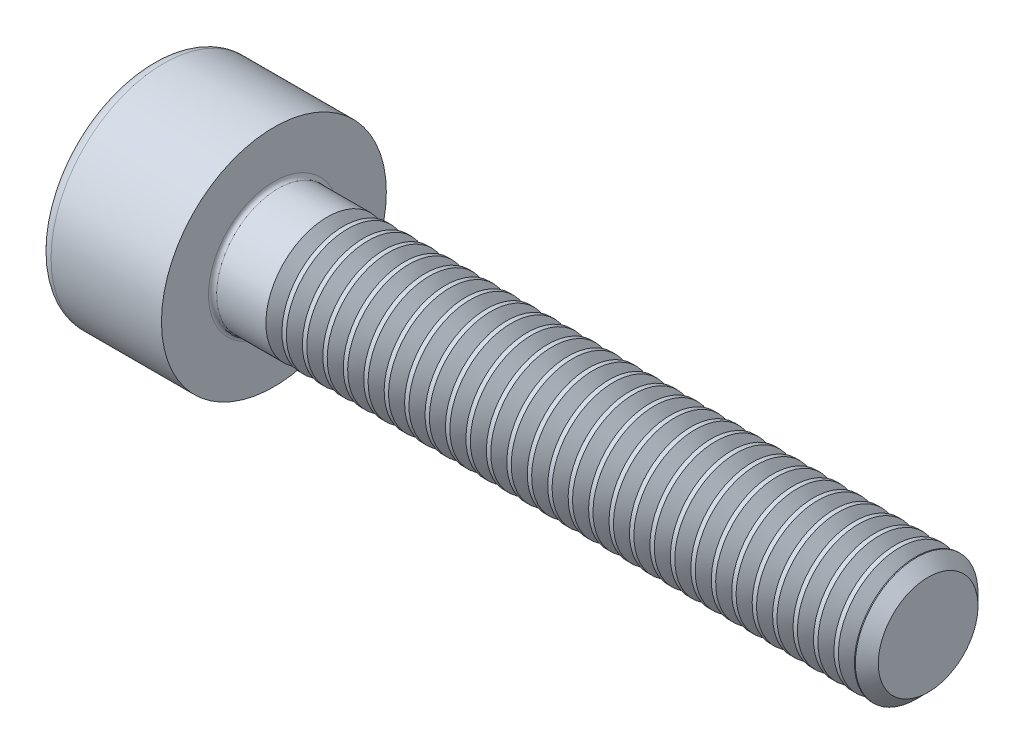
from build123d import *

# Parameters (mm, degrees)
FILLET1_R       = 0.1
FILLET2_R       = 0.3
HEX_2_DEPTH     = 1.3
THDSCHPAT_COUNT = 29
THDSCHPAT_PITCH = 0.5


with BuildPart() as part:
    # BodySke → Base-Revolve (revolve)
    with BuildSketch(Plane.XY, mode=Mode.PRIVATE) as base_revolve_sk:
        Polygon((0, 0), (0, 2.75), (3, 2.75), (3, 1.5), (18.7195, 1.5), (19, 1.2195), (19, 0), align=None)
    revolve(base_revolve_sk.sketch.rotate(Axis((-31.75, 0, 0), (1, 0, 0)), 90), axis=Axis((-31.75, 0, 0), (1, 0, 0)))  # turned: the seam where the file's is

    # Fillet1
    fillet1_edges = [part.edges().sort_by_distance(p)[0] for p in [
        (3, 0, -1.5),
    ]]
    fillet(fillet1_edges, radius=FILLET1_R)

    # Fillet2
    fillet2_edges = [part.edges().sort_by_distance(p)[0] for p in [
        (0, 0, -2.75),
    ]]
    fillet(fillet2_edges, radius=FILLET2_R)

    # Sketch2 → Hex-PreBroach (revolve, cut)
    with BuildSketch(Plane.XY, mode=Mode.PRIVATE) as hex_prebroach_sk:
        Polygon((0, 1.26), (1.3, 1.26), (2.027461339, 0), (0, 0), align=None)
    revolve(hex_prebroach_sk.sketch.rotate(Axis((0, 0, 0), (1, 0, 0)), 90), axis=Axis((0, 0, 0), (1, 0, 0)), mode=Mode.SUBTRACT)  # turned: the seam where the file's is

    # Sketch3 → Hex 2 (cut)
    with BuildSketch(Plane(origin=(0, 0, 0), x_dir=(0, 0.5, 0.866025404), z_dir=(-1, 0, 0))):
        Polygon((0.727461339, 1.26), (-0.727461339, 1.26), (-1.454922678, 0), (-0.727461339, -1.26), (0.727461339, -1.26), (1.454922678, 0), align=None)
    extrude(amount=-HEX_2_DEPTH, mode=Mode.SUBTRACT)

    # ThdSchSke → ThreadSchematic (revolve, cut)
    with BuildSketch(Plane.XY, mode=Mode.PRIVATE) as threadschematic_sk:
        Polygon((4.5, -1.2195), (4.303591786, -1.5), (4.303591786, -1.875), (4.696408214, -1.875), (4.696408214, -1.5), align=None)
    threadschematic = revolve(threadschematic_sk.sketch.rotate(Axis((-3.175, 0, 0), (1, 0, 0)), 270), axis=Axis((-3.175, 0, 0), (1, 0, 0)), mode=Mode.SUBTRACT)  # turned: the seam where the file's is

    # ThdSchPat: ThreadSchematic ×29
    with Locations(*[(i * THDSCHPAT_PITCH, 0, 0) for i in range(1, THDSCHPAT_COUNT)]):
        add(threadschematic, mode=Mode.SUBTRACT)


solid = part.part
